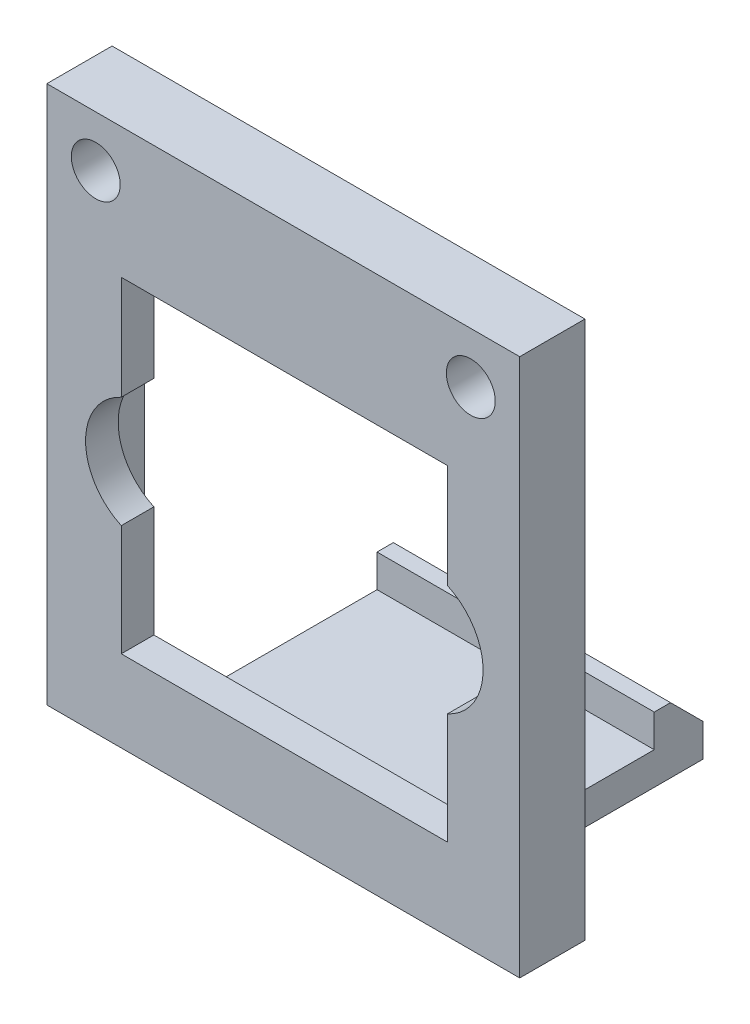
from build123d import *

# Parameters (mm, degrees)
SKETCH1_W           = 29
SKETCH1_H           = 55.5
BODY_DEPTH          = 4
SKETCH2_R           = 1.5
BOLT_HOLES_DEPTH    = 63.747509911
CUT_EXTRUDE1_DEPTH  = 10
SKETCH6_W           = 25
SKETCH6_H           = 25
CUT_EXTRUDE2_DEPTH  = 2
SKETCH7_W           = 17
SKETCH7_H           = 2
BOSS_EXTRUDE1_DEPTH = 10.25
BOSS_EXTRUDE2_DEPTH = 17


with BuildPart() as part:
    # Sketch1 → Body (new body)
    with BuildSketch(Plane.XY):
        with Locations((14.5, 27.75)):
            Rectangle(SKETCH1_W, SKETCH1_H)
    extrude(amount=BODY_DEPTH)

    # Sketch2 → Bolt Holes (cut, through all)
    with BuildSketch(Plane.XY.offset(4)):
        with Locations((3, 52.385)):
            Circle(SKETCH2_R)
        with Locations(Location((26, 52.385, 0), (0, 0, 180))):
            Circle(SKETCH2_R)
        with Locations((26, 3.115)):
            Circle(SKETCH2_R)
        with Locations(Location((3, 3.115, 0), (0, 0, 180))):
            Circle(SKETCH2_R)
    extrude(amount=-BOLT_HOLES_DEPTH, mode=Mode.SUBTRACT)

    # Sketch4 → Cut-Extrude1 (cut)
    with BuildSketch(Plane.XY):
        with BuildLine():
            Line((4.563898139, 34.308305648), (4.563898139, 27.5))
            Line((4.563898139, 27.5), (24.563898139, 27.5))
            Line((24.563898139, 27.5), (24.563898139, 34.308305648))
            ThreePointArc((24.563898139, 34.308305648), (26.753898139, 37.718422948), (24.563898139, 41.128540248))
            Line((24.563898139, 41.128540248), (24.563898139, 47.5))
            Line((24.563898139, 47.5), (4.563898139, 47.5))
            Line((4.563898139, 47.5), (4.563898139, 41.128540248))
            ThreePointArc((4.563898139, 41.128540248), (2.373898139, 37.718422948), (4.563898139, 34.308305648))
        make_face()
    extrude(amount=CUT_EXTRUDE1_DEPTH, mode=Mode.SUBTRACT)

    # Sketch6 → Cut-Extrude2 (cut)
    with BuildSketch(Plane(origin=(0, 0, 0), x_dir=(-1, 0, 0), z_dir=(0, 0, -1))):
        with Locations((-14.5, 37)):
            Rectangle(SKETCH6_W, SKETCH6_H)
    extrude(amount=-CUT_EXTRUDE2_DEPTH, mode=Mode.SUBTRACT)

    # Sketch7 → Boss-Extrude1 (add)
    with BuildSketch(Plane.XY):
        with Locations((14.5, 23.5)):
            Rectangle(SKETCH7_W, SKETCH7_H)
    extrude(amount=-BOSS_EXTRUDE1_DEPTH)

    # Sketch8 → Boss-Extrude2 (add)
    with BuildSketch(Plane(origin=(23, 0, 0), x_dir=(0, 0, -1), z_dir=(1, 0, 0))):
        Polygon((10.25, 22.5), (10.25, 26.5), (11.25, 26.5), (13.25, 24.5), (13.25, 22.5), align=None)
    extrude(amount=-BOSS_EXTRUDE2_DEPTH)

    # SurfaceCut1
    split(bisect_by=Plane(origin=(0, 22.5, 0), x_dir=(-1, 0, 0), z_dir=(0, -1, 0)), keep=Keep.BOTTOM)


solid = part.part
